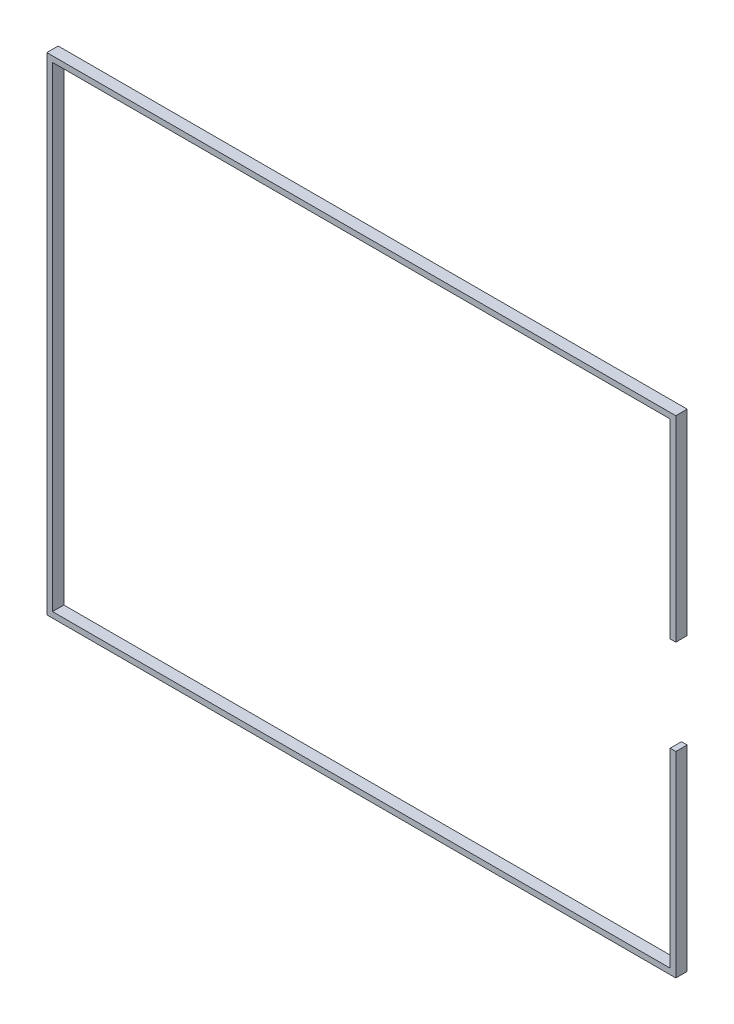
from build123d import *

# Parameters (mm, degrees)
IZIM1_W                     = 50
IZIM1_H                     = 50
IZIM1_H_2                   = 45
IZIM1_W_2                   = 45
Y_KSEKLIK_EKSTR_ZYON2_DEPTH = 5
IZIM2_R                     = 3
Y_KSEKLIK_EKSTR_ZYON3_DEPTH = 15
Y_KSEKLIK_EKSTR_ZYON4_DEPTH = 6
IZIM4_W                     = 15
IZIM4_H                     = 5
IZIM4_W_2                   = 5
IZIM4_H_2                   = 15
Y_KSEKLIK_EKSTR_ZYON5_DEPTH = 20
IZIM5_R                     = 2
KES_EKSTR_ZYON1_DEPTH       = 132.1
IZIM6_R                     = 2
KES_EKSTR_ZYON2_DEPTH       = 169.6
IZIM7_W                     = 393.876615126
IZIM7_H                     = 303.042246628
KES_EKSTR_ZYON3_DEPTH       = 26
KES_EKSTR_ZYON4_DEPTH       = 7


with BuildPart() as part:
    # Çizim1 → Yükseklik-Ekstrüzyon2 (new body)
    with BuildSketch(Plane.XY):
        Polygon((-35, -128.6), (-35, -116.312863708), (-52.209867178, -116.312863708), align=None)
        Polygon((-35, -116.312863708), (-148.890132822, -35), (-148.890132822, -47.287136292), (-52.209867178, -116.312863708), align=None)
        Polygon((-25, -35), (-35, -35), (-35, -116.312863708), (-35, -128.6), (35, -128.6), (35, -116.312863708), (35, -35), (25, -35), (25, -80), (25, -108.6), (-25, -108.6), (-25, -80), align=None)
        Polygon((-148.890132822, -47.287136292), (-166.1, -35), (-166.1, -128.6), (-35, -128.6), (-52.209867178, -116.312863708), (-148.890132822, -116.312863708), align=None)
        Polygon((-148.890132822, -35), (-166.1, -35), (-148.890132822, -47.287136292), align=None)
        Polygon((-35, 25), (-35, 35), (-148.890132822, 35), (-166.1, 35), (-166.1, -35), (-148.890132822, -35), (-35, -35), (-35, -25), (-80, -25), (-146.1, -25), (-146.1, 25), (-80, 25), align=None)
        Polygon((-25, 35), (-35, 35), (-35, 25), (-35, -25), (-35, -35), (-25, -35), (25, -35), (35, -35), (35, -25), (35, 25), (35, 35), (25, 35), align=None)
        Rectangle(IZIM1_W, IZIM1_H, mode=Mode.SUBTRACT)
        with Locations((0, -57.5)):
            Rectangle(IZIM1_W, IZIM1_H_2)
        Rectangle(IZIM1_W, IZIM1_H)
        with Locations((-57.5, 0)):
            Rectangle(IZIM1_W_2, IZIM1_H)
        with Locations((57.5, 0)):
            Rectangle(IZIM1_W_2, IZIM1_H)
        Polygon((148.890132822, 35), (35, 35), (35, 25), (80, 25), (146.1, 25), (146.1, -25), (80, -25), (35, -25), (35, -35), (148.890132822, -35), (166.1, -35), (166.1, 35), align=None)
        Polygon((148.890132822, -47.287136292), (148.890132822, -35), (35, -116.312863708), (52.209867178, -116.312863708), align=None)
        Polygon((148.890132822, -47.287136292), (166.1, -35), (148.890132822, -35), align=None)
        Polygon((166.1, -128.6), (166.1, -35), (148.890132822, -47.287136292), (148.890132822, -116.312863708), (52.209867178, -116.312863708), (35, -128.6), align=None)
        Polygon((52.209867178, -116.312863708), (35, -116.312863708), (35, -128.6), align=None)
        Polygon((52.209867178, 116.312863708), (35, 116.312863708), (148.890132822, 35), (148.890132822, 47.287136292), align=None)
        Polygon((148.890132822, 47.287136292), (148.890132822, 35), (166.1, 35), align=None)
        Polygon((166.1, 128.6), (35, 128.6), (52.209867178, 116.312863708), (148.890132822, 116.312863708), (148.890132822, 47.287136292), (166.1, 35), align=None)
        Polygon((52.209867178, 116.312863708), (35, 128.6), (35, 116.312863708), align=None)
        Polygon((35, 128.6), (-35, 128.6), (-35, 116.312863708), (-35, 35), (-25, 35), (-25, 80), (-25, 108.6), (25, 108.6), (25, 80), (25, 35), (35, 35), (35, 116.312863708), align=None)
        with Locations((0, 57.5)):
            Rectangle(IZIM1_W, IZIM1_H_2)
        Polygon((-35, 116.312863708), (-35, 128.6), (-52.209867178, 116.312863708), align=None)
        Polygon((-35, 116.312863708), (-52.209867178, 116.312863708), (-148.890132822, 47.287136292), (-148.890132822, 35), align=None)
        Polygon((-52.209867178, 116.312863708), (-35, 128.6), (-166.1, 128.6), (-166.1, 35), (-148.890132822, 47.287136292), (-148.890132822, 116.312863708), align=None)
        Polygon((-148.890132822, 35), (-148.890132822, 47.287136292), (-166.1, 35), align=None)
    extrude(amount=-Y_KSEKLIK_EKSTR_ZYON2_DEPTH)

    # Çizim2 → Yükseklik-Ekstrüzyon3 (add)
    with BuildSketch(Plane(origin=(0, 0, -5), x_dir=(-1, 0, 0), z_dir=(0, 0, -1))):
        Circle(IZIM2_R)
    extrude(amount=Y_KSEKLIK_EKSTR_ZYON3_DEPTH)

    # Çizim3 → Yükseklik-Ekstrüzyon4 (add)
    with BuildSketch(Plane.XY):
        Polygon((161.1, 123.6), (161.1, 25), (166.1, 25), (166.1, 128.6), (-166.1, 128.6), (-166.1, -128.6), (166.1, -128.6), (166.1, -25), (161.1, -25), (161.1, -123.6), (-161.1, -123.6), (-161.1, 123.6), align=None)
    extrude(amount=Y_KSEKLIK_EKSTR_ZYON4_DEPTH)

    # Çizim4 → Yükseklik-Ekstrüzyon5 (add)
    with BuildSketch(Plane(origin=(0, 0, -5), x_dir=(-1, 0, 0), z_dir=(0, 0, -1))):
        with Locations((-60, 0)):
            Rectangle(IZIM4_W, IZIM4_H)
        with Locations((0, -60)):
            Rectangle(IZIM4_W_2, IZIM4_H_2)
    extrude(amount=Y_KSEKLIK_EKSTR_ZYON5_DEPTH)

    # Çizim5 → Kes-Ekstrüzyon1 (cut, through all)
    with BuildSketch(Plane.XZ.offset(2.5)):
        with Locations((60, -10)):
            Circle(IZIM5_R)
        with Locations((60, -19)):
            Circle(IZIM5_R)
    extrude(amount=-KES_EKSTR_ZYON1_DEPTH, mode=Mode.SUBTRACT)

    # Çizim6 → Kes-Ekstrüzyon2 (cut, through all)
    with BuildSketch(Plane(origin=(2.5, 0, 0), x_dir=(0, 0, -1), z_dir=(1, 0, 0))):
        with Locations((10, -60)):
            Circle(IZIM6_R)
        with Locations((19, -60)):
            Circle(IZIM6_R)
    extrude(amount=-KES_EKSTR_ZYON2_DEPTH, mode=Mode.SUBTRACT)

    # Çizim7 → Kes-Ekstrüzyon3 (cut, through all)
    with BuildSketch(Plane.XY):
        with Locations((1.174582351, -1.957637252)):
            Rectangle(IZIM7_W, IZIM7_H)
    extrude(amount=-KES_EKSTR_ZYON3_DEPTH, mode=Mode.SUBTRACT)

    # Çizim8 → Kes-Ekstrüzyon4 (cut, through all)
    with BuildSketch(Plane.XY.offset(6)):
        Polygon((161.1, 25), (163.1, 25), (163.1, 125.6), (-163.1, 125.6), (-163.1, -125.6), (163.1, -125.6), (163.1, -25), (161.1, -25), (161.1, -123.6), (-161.1, -123.6), (-161.1, 123.6), (161.1, 123.6), align=None)
    extrude(amount=-KES_EKSTR_ZYON4_DEPTH, mode=Mode.SUBTRACT)


solid = part.part
